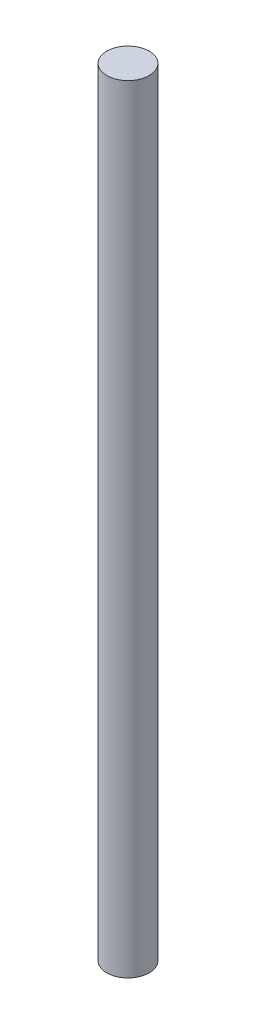
from build123d import *

# Parameters (mm, degrees)
SKETCH1_R           = 1.5
BOSS_EXTRUDE1_DEPTH = 55


with BuildPart() as part:
    # Sketch1 → Boss-Extrude1 (new body)
    with BuildSketch(Plane(origin=(0, 0, 0), x_dir=(1, 0, 0), z_dir=(0, 1, 0))):
        Circle(SKETCH1_R)
    extrude(amount=BOSS_EXTRUDE1_DEPTH)


solid = part.part
